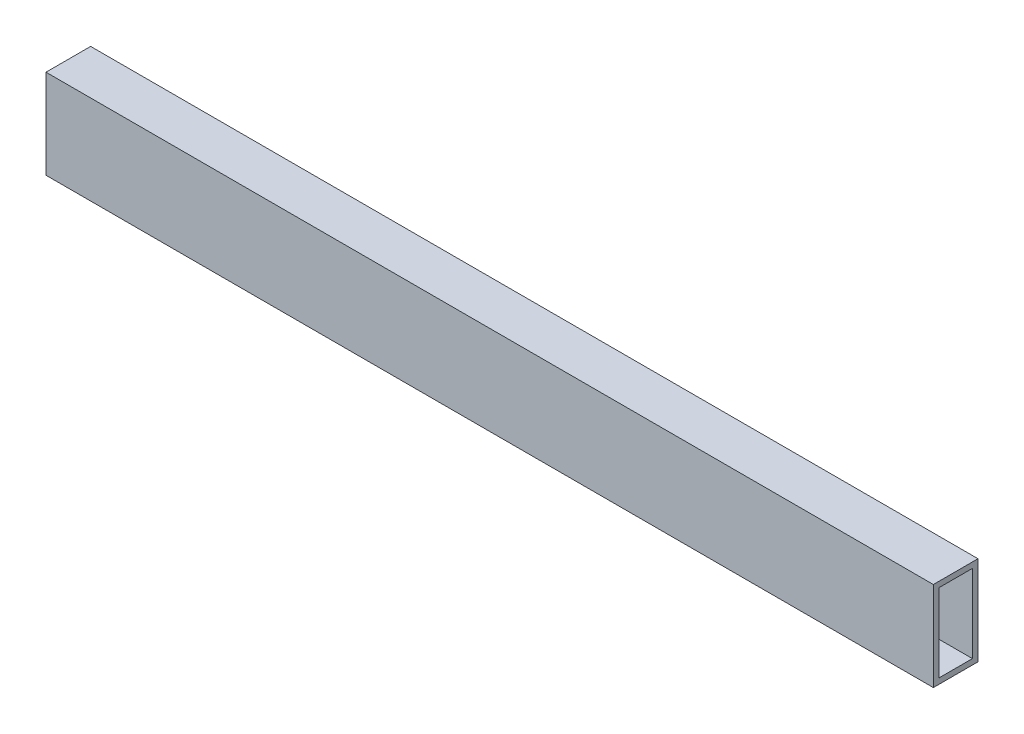
from build123d import *

# Parameters (mm, degrees)
SKETCH1_W           = 25.4
SKETCH1_H           = 50.8
SKETCH1_W_2         = 19.05
SKETCH1_H_2         = 44.45
BOSS_EXTRUDE1_DEPTH = 504.825


with BuildPart() as part:
    # Sketch1 → Boss-Extrude1 (new body)
    with BuildSketch(Plane(origin=(0, 0, 0), x_dir=(0, 0, -1), z_dir=(1, 0, 0))):
        with Locations((12.7, 25.4)):
            Rectangle(SKETCH1_W, SKETCH1_H)
        with Locations((12.7, 25.4)):
            Rectangle(SKETCH1_W_2, SKETCH1_H_2, mode=Mode.SUBTRACT)
    extrude(amount=BOSS_EXTRUDE1_DEPTH)


solid = part.part
